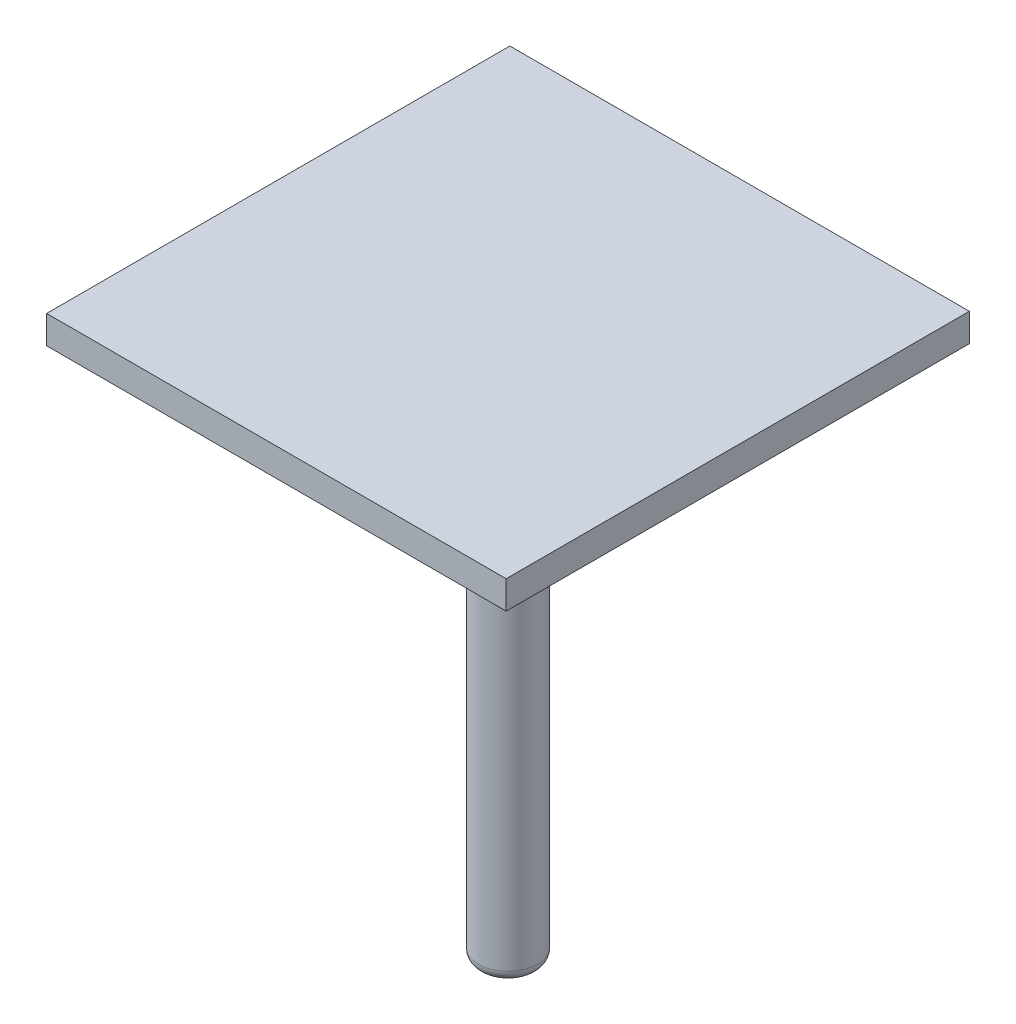
from build123d import *

# Parameters (mm, degrees)
SKETCH1_R           = 1.05
BOSS_EXTRUDE1_DEPTH = 16.5
SKETCH2_R           = 2
BOSS_EXTRUDE2_DEPTH = 2.5
FILLET1_R           = 0.4
FILLET2_R           = 1
SKETCH3_W           = 16.37962499
SKETCH3_H           = 16.511817854
BOSS_EXTRUDE3_DEPTH = 1


with BuildPart() as part:
    # Sketch1 → Boss-Extrude1 (new body)
    with BuildSketch(Plane(origin=(0, 0, 0), x_dir=(1, 0, 0), z_dir=(0, 1, 0))):
        Circle(SKETCH1_R)
    extrude(amount=BOSS_EXTRUDE1_DEPTH)

    # Sketch2 → Boss-Extrude2 (add)
    with BuildSketch(Plane(origin=(0, 16.5, 0), x_dir=(1, 0, 0), z_dir=(0, 1, 0))):
        Circle(SKETCH2_R)
    extrude(amount=BOSS_EXTRUDE2_DEPTH)

    # Fillet1
    fillet1_edges = [part.edges().sort_by_distance(p)[0] for p in [
        (-1.05, 0, 0),
    ]]
    fillet(fillet1_edges, radius=FILLET1_R)

    # Fillet2
    fillet2_edges = [part.edges().sort_by_distance(p)[0] for p in [
        (-2, 19, 0),
    ]]
    fillet(fillet2_edges, radius=FILLET2_R)

    # Sketch3 → Boss-Extrude3 (add)
    with BuildSketch(Plane(origin=(0, 19, 0), x_dir=(1, 0, 0), z_dir=(0, 1, 0))):
        Rectangle(SKETCH3_W, SKETCH3_H)
    extrude(amount=BOSS_EXTRUDE3_DEPTH)


solid = part.part
